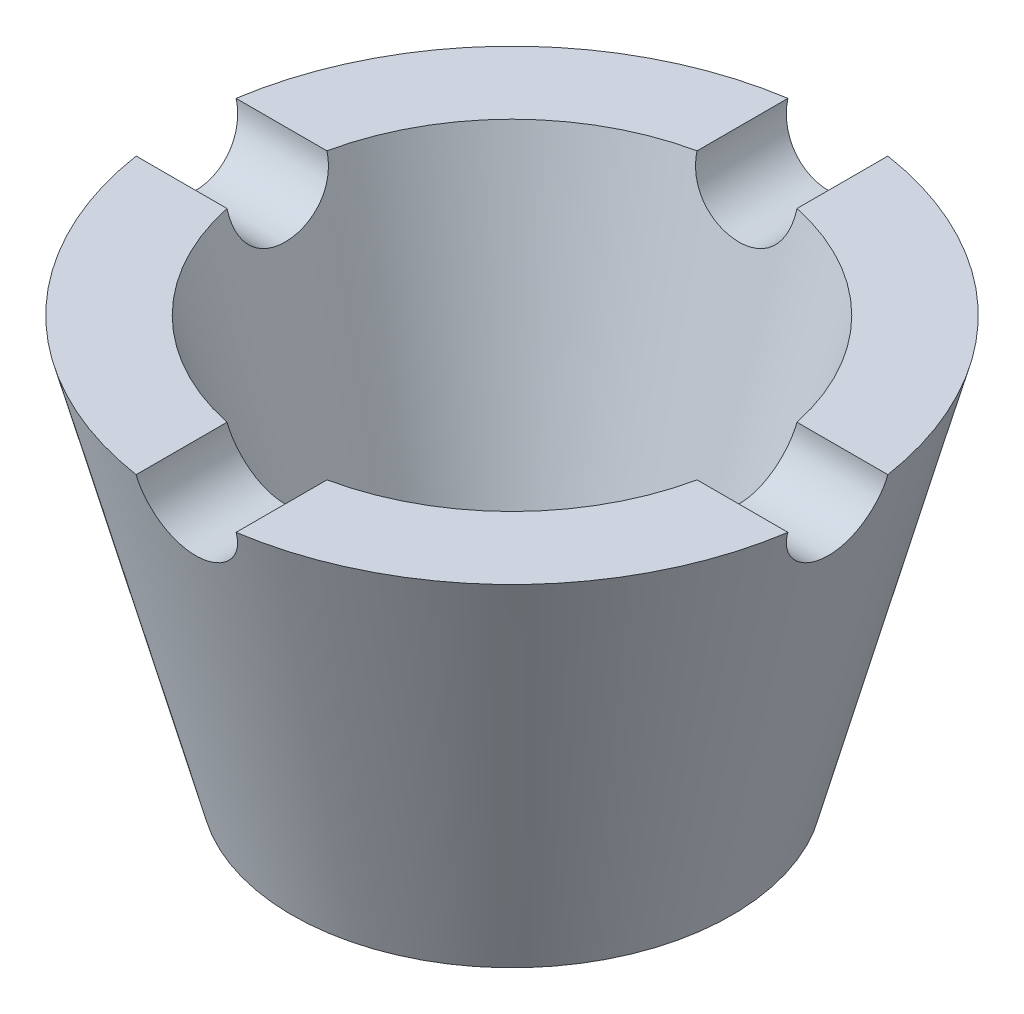
from build123d import *

# Parameters (mm, degrees)
CUT_EXTRUDE1_DEPTH      = 34
CUT_EXTRUDE1_DEPTH_BACK = 34
CUT_EXTRUDE2_DEPTH      = 34.0000001
CUT_EXTRUDE2_DEPTH_BACK = 34.0000001


with BuildPart() as part:
    # Sketch1 → Revolve1 (revolve)
    with BuildSketch(Plane.XY, mode=Mode.PRIVATE) as revolve1_sk:
        Polygon((-11, 0), (-22, 0), (-33, 41), (-24.048780488, 41), (-16, 11), (-11, 11), align=None)
    revolve(revolve1_sk.sketch.rotate(Axis((0, 0, 0), (0, 1, 0)), 270), axis=Axis((0, 0, 0), (0, 1, 0)))  # turned: the seam where the file's is

    # Sketch2 → Cut-Extrude1 (cut, two sides)
    with BuildSketch(Plane.XY) as cut_extrude1_sk:
        with BuildLine():
            Line((-5, 41), (5, 41))
            ThreePointArc((5, 41), (0, 36), (-5, 41))
        make_face()
    extrude(amount=CUT_EXTRUDE1_DEPTH, mode=Mode.SUBTRACT)
    extrude(cut_extrude1_sk.sketch, amount=-CUT_EXTRUDE1_DEPTH_BACK, mode=Mode.SUBTRACT)

    # Sketch3 → Cut-Extrude2 (cut, two sides)
    with BuildSketch(Plane(origin=(0, 0, 0), x_dir=(0, 0, -1), z_dir=(1, 0, 0))) as cut_extrude2_sk:
        with BuildLine():
            Line((-5, 41), (5, 41))
            ThreePointArc((5, 41), (0, 36), (-5, 41))
        make_face()
    extrude(amount=CUT_EXTRUDE2_DEPTH, mode=Mode.SUBTRACT)
    extrude(cut_extrude2_sk.sketch, amount=-CUT_EXTRUDE2_DEPTH_BACK, mode=Mode.SUBTRACT)


solid = part.part
